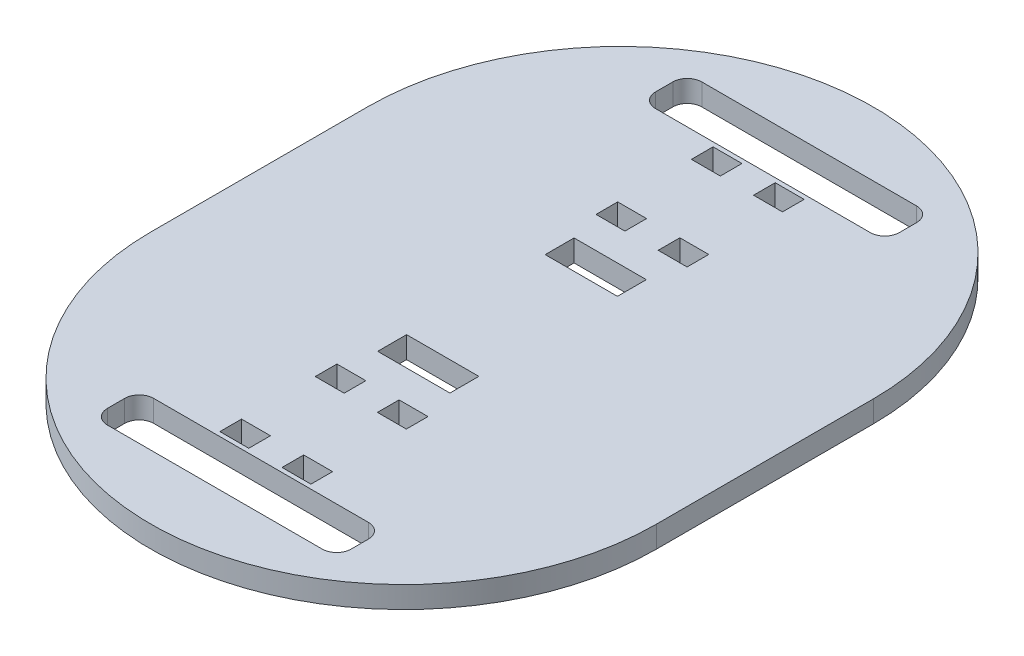
from build123d import *

# Parameters (mm, degrees)
BOSS_EXTRUDE1_DEPTH     = 7.62
SKETCH2_W               = 85.677392152
SKETCH2_H               = 16.256
CUT_EXTRUDE1_DEPTH      = 1
CUT_EXTRUDE1_DEPTH_BACK = 8.62
FILLET1_R               = 5.08
SKETCH3_W               = 10.16
SKETCH3_H               = 7.62
CUT_EXTRUDE2_DEPTH      = 8.62
SKETCH4_W               = 25.4
SKETCH4_H               = 10.16
CUT_EXTRUDE3_DEPTH      = 8.62


with BuildPart() as part:
    # Sketch1 → Boss-Extrude1 (new body)
    with BuildSketch(Plane(origin=(0, 0, 0), x_dir=(1, 0, 0), z_dir=(0, 1, 0))):
        with BuildLine():
            Line((-88.9, 0), (-88.9, 76.2))
            ThreePointArc((-88.9, 76.2), (0, 165.1), (88.9, 76.2))
            Line((88.9, 76.2), (88.9, 0))
            ThreePointArc((88.9, 0), (0, -88.9), (-88.9, 0))
        make_face()
    extrude(amount=BOSS_EXTRUDE1_DEPTH)

    # Sketch2 → Cut-Extrude1 (cut, two sides)
    with BuildSketch(Plane(origin=(0, 7.62, 0), x_dir=(1, 0, 0), z_dir=(0, 1, 0))) as cut_extrude1_sk:
        with Locations((0, -58.235236409)):
            Rectangle(SKETCH2_W, SKETCH2_H)
        with Locations((0, 134.435236409)):
            Rectangle(SKETCH2_W, SKETCH2_H)
    extrude(amount=CUT_EXTRUDE1_DEPTH, mode=Mode.SUBTRACT)
    extrude(cut_extrude1_sk.sketch, amount=-CUT_EXTRUDE1_DEPTH_BACK, mode=Mode.SUBTRACT)

    # Fillet1
    fillet1_edges = [part.edges().sort_by_distance(p)[0] for p in [
        (-42.838696076, 3.81, 66.363236409),
        (-42.838696076, 3.81, 50.107236409),
        (42.838696076, 3.81, 50.107236409),
        (42.838696076, 3.81, 66.363236409),
        (-42.838696076, 3.81, -126.307236409),
        (-42.838696076, 3.81, -142.563236409),
        (42.838696076, 3.81, -142.563236409),
        (42.838696076, 3.81, -126.307236409),
    ]]
    fillet(fillet1_edges, radius=FILLET1_R)

    # Sketch3 → Cut-Extrude2 (cut, through all)
    with BuildSketch(Plane(origin=(0, 7.62, 0), x_dir=(1, 0, 0), z_dir=(0, 1, 0))):
        with Locations((10.922, 87.445236409)):
            Rectangle(SKETCH3_W, SKETCH3_H)
        with Locations((-10.922, 87.445236409)):
            Rectangle(SKETCH3_W, SKETCH3_H)
        with Locations((10.922, 120.973236409)):
            Rectangle(SKETCH3_W, SKETCH3_H)
        with Locations((-10.922, 120.973236409)):
            Rectangle(SKETCH3_W, SKETCH3_H)
        with Locations((-10.922, -11.245236409)):
            Rectangle(SKETCH3_W, SKETCH3_H)
        with Locations((10.922, -11.245236409)):
            Rectangle(SKETCH3_W, SKETCH3_H)
        with Locations((-10.922, -44.773236409)):
            Rectangle(SKETCH3_W, SKETCH3_H)
        with Locations((10.922, -44.773236409)):
            Rectangle(SKETCH3_W, SKETCH3_H)
    extrude(amount=-CUT_EXTRUDE2_DEPTH, mode=Mode.SUBTRACT)

    # Sketch4 → Cut-Extrude3 (cut, through all)
    with BuildSketch(Plane(origin=(0, 7.62, 0), x_dir=(1, 0, 0), z_dir=(0, 1, 0))):
        with Locations((0, 67.537940424)):
            Rectangle(SKETCH4_W, SKETCH4_H)
        with Locations((0, 8.662059576)):
            Rectangle(SKETCH4_W, SKETCH4_H)
    extrude(amount=-CUT_EXTRUDE3_DEPTH, mode=Mode.SUBTRACT)


solid = part.part
